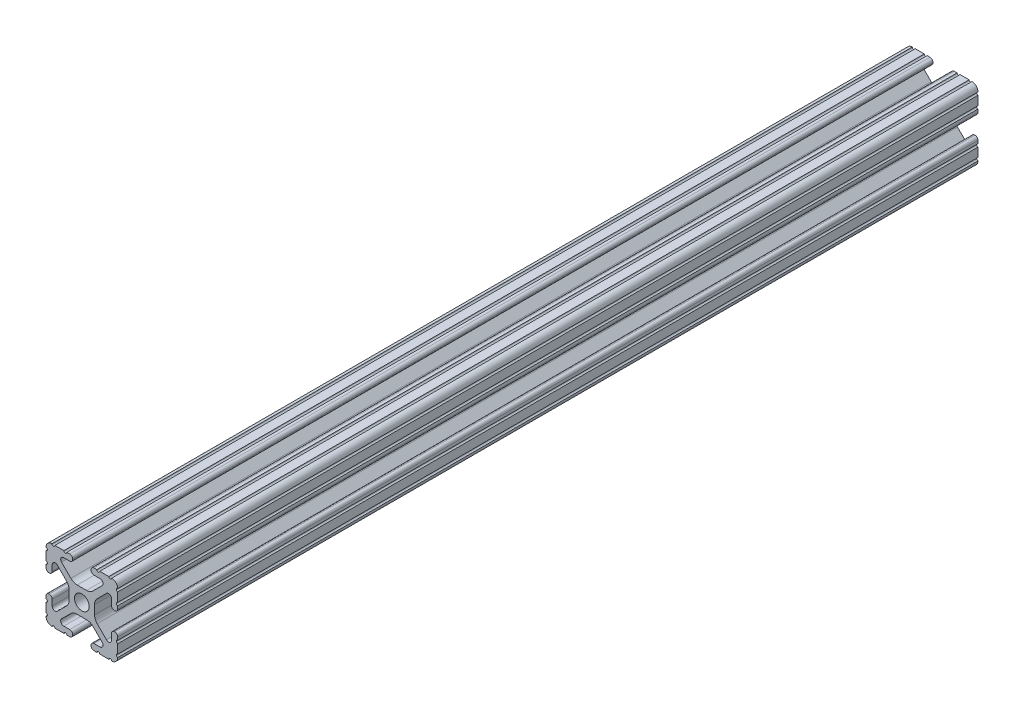
from build123d import *

# Parameters (mm, degrees)
SKETCH1_R      = 2.6035
EXTRUDE1_DEPTH = 304.8


with BuildPart() as part:
    # Sketch1 → Extrude1 (new body)
    with BuildSketch(Plane.XY):
        with BuildLine():
            Line((-7.207191475, 8.724540082), (-3.900315394, 5.423689619))
            ThreePointArc((-3.900315394, 5.423689619), (-2.8709819, 4.736928798), (-1.657299581, 4.4958))
            Line((-1.657299581, 4.4958), (1.657299581, 4.4958))
            ThreePointArc((1.657299581, 4.4958), (2.8709819, 4.736928798), (3.900315394, 5.423689619))
            Line((3.900315394, 5.423689619), (7.207191475, 8.724540082))
            ThreePointArc((7.207191475, 8.724540082), (7.43216212, 9.851515102), (6.476774195, 10.4902))
            Line((6.476774195, 10.4902), (4.2874692, 10.4902))
            ThreePointArc((4.2874692, 10.4902), (3.545700044, 10.797450844), (3.2384492, 11.53922))
            Line((3.2384492, 11.53922), (3.2384492, 11.65098))
            ThreePointArc((3.2384492, 11.65098), (3.545700044, 12.392749156), (4.2874692, 12.7))
            Line((4.2874692, 12.7), (5.3170836, 12.7))
            ThreePointArc((5.3170836, 12.7), (5.8250836, 12.192), (6.3330836, 12.7))
            Line((6.3330836, 12.7), (9.5504, 12.7))
            ThreePointArc((9.5504, 12.7), (10.058323491, 12.192000006), (10.566399977, 12.699846982))
            ThreePointArc((10.566399977, 12.699846982), (12.082522516, 12.082522516), (12.699846982, 10.566399977))
            ThreePointArc((12.699846982, 10.566399977), (12.192000006, 10.058323491), (12.7, 9.5504))
            Line((12.7, 9.5504), (12.7, 6.3331344))
            ThreePointArc((12.7, 6.3331344), (12.192, 5.8251344), (12.7, 5.3171344))
            Line((12.7, 5.3171344), (12.7, 4.287470133))
            ThreePointArc((12.7, 4.287470133), (12.392749156, 3.545700977), (11.65098, 3.238450133))
            Line((11.65098, 3.238450133), (11.53922, 3.238450133))
            ThreePointArc((11.53922, 3.238450133), (10.797450844, 3.545700977), (10.4902, 4.287470133))
            Line((10.4902, 4.287470133), (10.4902, 6.402089023))
            ThreePointArc((10.4902, 6.402089023), (9.856394933, 7.351113629), (8.736962546, 7.129240479))
            Line((8.736962546, 7.129240479), (5.440484187, 3.838768792))
            ThreePointArc((5.440484187, 3.838768792), (4.75073678, 2.808015636), (4.5085, 1.591658411))
            Line((4.5085, 1.591658411), (4.5085, -1.591658411))
            ThreePointArc((4.5085, -1.591658411), (4.75073678, -2.808015636), (5.440484187, -3.838768792))
            Line((5.440484187, -3.838768792), (8.736962546, -7.129240479))
            ThreePointArc((8.736962546, -7.129240479), (9.856394933, -7.351113629), (10.4902, -6.402089023))
            Line((10.4902, -6.402089023), (10.4902, -4.287470133))
            ThreePointArc((10.4902, -4.287470133), (10.797450844, -3.545700977), (11.53922, -3.238450133))
            Line((11.53922, -3.238450133), (11.65098, -3.238450133))
            ThreePointArc((11.65098, -3.238450133), (12.392749156, -3.545700977), (12.7, -4.287470133))
            Line((12.7, -4.287470133), (12.7, -5.3170836))
            ThreePointArc((12.7, -5.3170836), (12.192, -5.8250836), (12.7, -6.3330836))
            Line((12.7, -6.3330836), (12.7, -9.5504))
            ThreePointArc((12.7, -9.5504), (12.192000006, -10.058323491), (12.699846982, -10.566399977))
            ThreePointArc((12.699846982, -10.566399977), (12.082522516, -12.082522516), (10.566399977, -12.699846982))
            ThreePointArc((10.566399977, -12.699846982), (10.058323491, -12.192000006), (9.5504, -12.7))
            Line((9.5504, -12.7), (6.3331344, -12.7))
            ThreePointArc((6.3331344, -12.7), (5.8251344, -12.192), (5.3171344, -12.7))
            Line((5.3171344, -12.7), (4.28752, -12.7))
            ThreePointArc((4.28752, -12.7), (3.545750844, -12.392749156), (3.2385, -11.65098))
            Line((3.2385, -11.65098), (3.2385, -11.53922))
            ThreePointArc((3.2385, -11.53922), (3.545750844, -10.797450844), (4.28752, -10.4902))
            Line((4.28752, -10.4902), (6.41641086, -10.4902))
            ThreePointArc((6.41641086, -10.4902), (7.414733441, -9.822812921), (7.179652728, -8.645192207))
            Line((7.179652728, -8.645192207), (3.95226937, -5.423689619))
            ThreePointArc((3.95226937, -5.423689619), (2.922935876, -4.736928798), (1.709253557, -4.4958))
            Line((1.709253557, -4.4958), (-1.709253557, -4.4958))
            ThreePointArc((-1.709253557, -4.4958), (-2.922935876, -4.736928798), (-3.95226937, -5.423689619))
            Line((-3.95226937, -5.423689619), (-7.179652728, -8.645192207))
            ThreePointArc((-7.179652728, -8.645192207), (-7.414733441, -9.822812921), (-6.41641086, -10.4902))
            Line((-6.41641086, -10.4902), (-4.28752, -10.4902))
            ThreePointArc((-4.28752, -10.4902), (-3.545750844, -10.797450844), (-3.2385, -11.53922))
            Line((-3.2385, -11.53922), (-3.2385, -11.65098))
            ThreePointArc((-3.2385, -11.65098), (-3.545750844, -12.392749156), (-4.28752, -12.7))
            Line((-4.28752, -12.7), (-5.3171344, -12.7))
            ThreePointArc((-5.3171344, -12.7), (-5.8251344, -12.192), (-6.3331344, -12.7))
            Line((-6.3331344, -12.7), (-9.5504, -12.7))
            ThreePointArc((-9.5504, -12.7), (-10.058323491, -12.192000006), (-10.566399977, -12.699846982))
            ThreePointArc((-10.566399977, -12.699846982), (-12.082522516, -12.082522516), (-12.699846982, -10.566399977))
            ThreePointArc((-12.699846982, -10.566399977), (-12.192000006, -10.058323491), (-12.7, -9.5504))
            Line((-12.7, -9.5504), (-12.7, -6.3330836))
            ThreePointArc((-12.7, -6.3330836), (-12.192, -5.8250836), (-12.7, -5.3170836))
            Line((-12.7, -5.3170836), (-12.7, -4.287470133))
            ThreePointArc((-12.7, -4.287470133), (-12.392749156, -3.545700977), (-11.65098, -3.238450133))
            Line((-11.65098, -3.238450133), (-11.53922, -3.238450133))
            ThreePointArc((-11.53922, -3.238450133), (-10.797450844, -3.545700977), (-10.4902, -4.287470133))
            Line((-10.4902, -4.287470133), (-10.4902, -6.402089023))
            ThreePointArc((-10.4902, -6.402089023), (-9.856394933, -7.351113629), (-8.736962546, -7.129240479))
            Line((-8.736962546, -7.129240479), (-5.440484187, -3.838768792))
            ThreePointArc((-5.440484187, -3.838768792), (-4.75073678, -2.808015636), (-4.5085, -1.591658411))
            Line((-4.5085, -1.591658411), (-4.5085, 1.591658411))
            ThreePointArc((-4.5085, 1.591658411), (-4.75073678, 2.808015636), (-5.440484187, 3.838768792))
            Line((-5.440484187, 3.838768792), (-8.736962546, 7.129240479))
            ThreePointArc((-8.736962546, 7.129240479), (-9.856394933, 7.351113629), (-10.4902, 6.402089023))
            Line((-10.4902, 6.402089023), (-10.4902, 4.287470133))
            ThreePointArc((-10.4902, 4.287470133), (-10.797450844, 3.545700977), (-11.53922, 3.238450133))
            Line((-11.53922, 3.238450133), (-11.65098, 3.238450133))
            ThreePointArc((-11.65098, 3.238450133), (-12.392749156, 3.545700977), (-12.7, 4.287470133))
            Line((-12.7, 4.287470133), (-12.7, 5.3171344))
            ThreePointArc((-12.7, 5.3171344), (-12.192, 5.8251344), (-12.7, 6.3331344))
            Line((-12.7, 6.3331344), (-12.7, 9.5504))
            ThreePointArc((-12.7, 9.5504), (-12.192000006, 10.058323491), (-12.699846982, 10.566399977))
            ThreePointArc((-12.699846982, 10.566399977), (-12.082522516, 12.082522516), (-10.566399977, 12.699846982))
            ThreePointArc((-10.566399977, 12.699846982), (-10.058323491, 12.192000006), (-9.5504, 12.7))
            Line((-9.5504, 12.7), (-6.3330836, 12.7))
            ThreePointArc((-6.3330836, 12.7), (-5.8250836, 12.192), (-5.3170836, 12.7))
            Line((-5.3170836, 12.7), (-4.2874692, 12.7))
            ThreePointArc((-4.2874692, 12.7), (-3.545700044, 12.392749156), (-3.2384492, 11.65098))
            Line((-3.2384492, 11.65098), (-3.2384492, 11.53922))
            ThreePointArc((-3.2384492, 11.53922), (-3.545700044, 10.797450844), (-4.2874692, 10.4902))
            Line((-4.2874692, 10.4902), (-6.476774195, 10.4902))
            ThreePointArc((-6.476774195, 10.4902), (-7.43216212, 9.851515102), (-7.207191475, 8.724540082))
        make_face()
        Circle(SKETCH1_R, mode=Mode.SUBTRACT)
    extrude(amount=-EXTRUDE1_DEPTH)


solid = part.part
